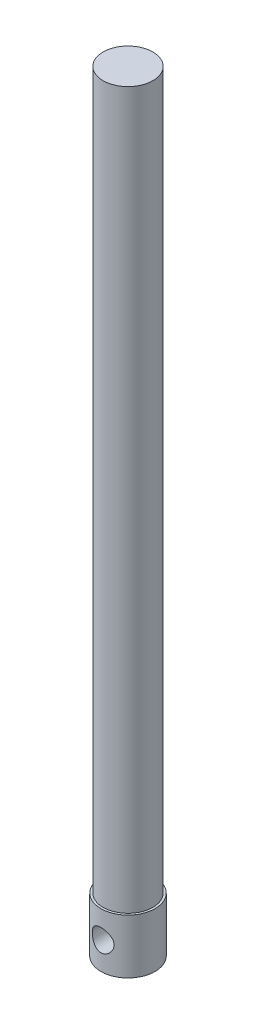
from build123d import *

# Parameters (mm, degrees)
SKETCH1_R               = 3.937
BOSS_EXTRUDE1_DEPTH     = 7.9248
SKETCH3_R               = 3.6195
BOSS_EXTRUDE2_DEPTH     = 104.14
SKETCH4_R               = 1.5875
CUT_EXTRUDE1_DEPTH      = 4.937
CUT_EXTRUDE1_DEPTH_BACK = 4.937


with BuildPart() as part:
    # Sketch1 → Boss-Extrude1 (new body)
    with BuildSketch(Plane(origin=(0, 0, 0), x_dir=(1, 0, 0), z_dir=(0, 1, 0))):
        Circle(SKETCH1_R)
    extrude(amount=BOSS_EXTRUDE1_DEPTH)

    # Sketch3 → Boss-Extrude2 (add)
    with BuildSketch(Plane(origin=(0, 7.9248, 0), x_dir=(1, 0, 0), z_dir=(0, 1, 0))):
        Circle(SKETCH3_R)
    extrude(amount=BOSS_EXTRUDE2_DEPTH)

    # Sketch4 → Cut-Extrude1 (cut, two sides)
    with BuildSketch(Plane.XY) as cut_extrude1_sk:
        with Locations((0, 3.9624)):
            Circle(SKETCH4_R)
    extrude(amount=CUT_EXTRUDE1_DEPTH, mode=Mode.SUBTRACT)
    extrude(cut_extrude1_sk.sketch, amount=-CUT_EXTRUDE1_DEPTH_BACK, mode=Mode.SUBTRACT)


solid = part.part
